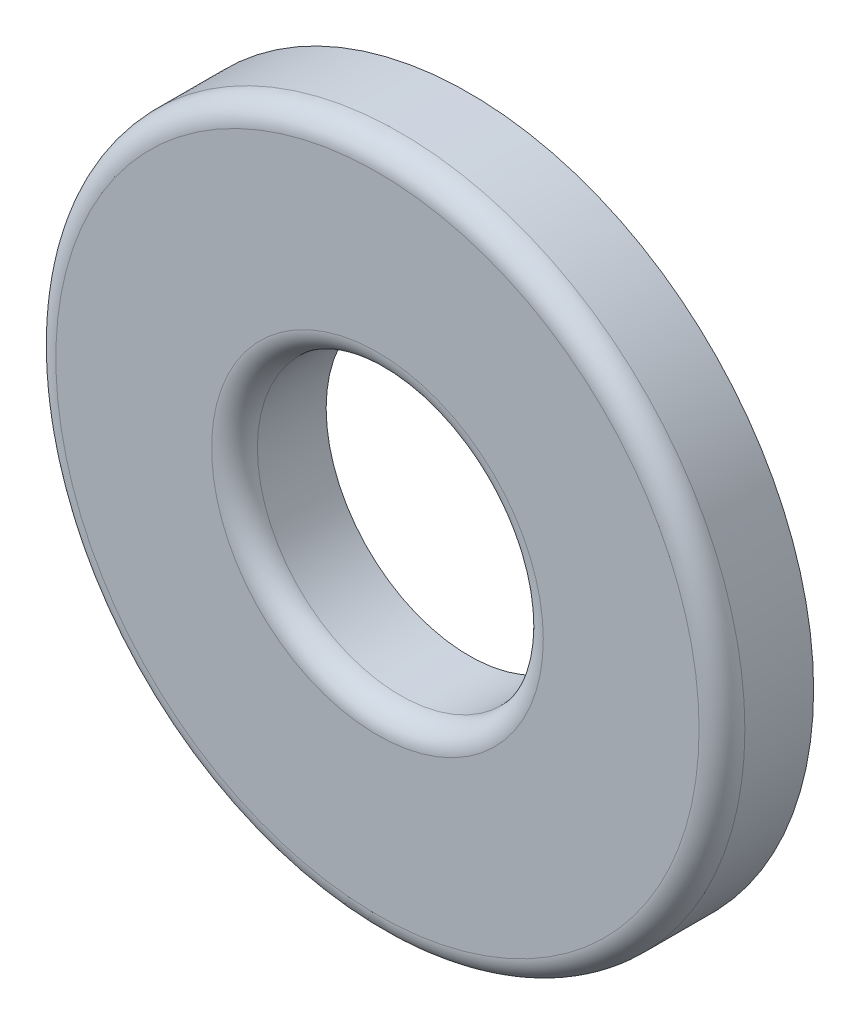
from build123d import *

# Parameters (mm, degrees)
SKETCH3_R                = 2.3876
SKETCH3_R_2              = 0.9906
BOSS_EXTRUDE1_DEPTH      = 0.3175
BOSS_EXTRUDE1_DEPTH_BACK = 0.3175
FILLET1_R                = 0.15875


with BuildPart() as part:
    # Sketch3 → Boss-Extrude1 (new body, two sides)
    with BuildSketch(Plane.XY) as boss_extrude1_sk:
        Circle(SKETCH3_R)
        Circle(SKETCH3_R_2, mode=Mode.SUBTRACT)
    extrude(amount=BOSS_EXTRUDE1_DEPTH)
    extrude(boss_extrude1_sk.sketch, amount=-BOSS_EXTRUDE1_DEPTH_BACK)

    # Fillet1
    fillet1_edges = [part.edges().sort_by_distance(p)[0] for p in [
        (-2.3876, 0, 0.3175),
        (-0.9906, 0, 0.3175),
    ]]
    fillet(fillet1_edges, radius=FILLET1_R)


solid = part.part
